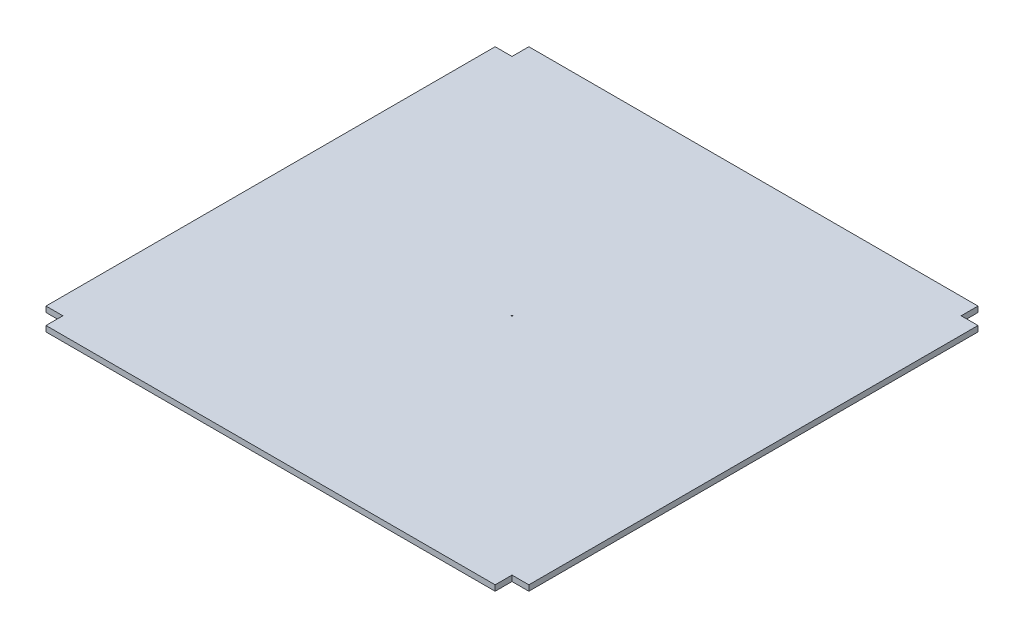
from build123d import *

# Parameters (mm, degrees)
BOSS_EXTRUDE1_DEPTH     = 10
SKETCH2_R               = 1
CUT_EXTRUDE1_DEPTH      = 1
CUT_EXTRUDE1_DEPTH_BACK = 11


with BuildPart() as part:
    # Sketch1 → Boss-Extrude1 (new body)
    with BuildSketch(Plane(origin=(0, 0, 0), x_dir=(1, 0, 0), z_dir=(0, 1, 0))):
        Polygon((-400, -430), (400, -430), (400, -400), (430, -400), (430, 400), (400, 400), (400, 430), (-400, 430), (-400, 400), (-430, 400), (-430, -400), (-400, -400), align=None)
    extrude(amount=BOSS_EXTRUDE1_DEPTH)

    # Sketch2 → Cut-Extrude1 (cut, two sides)
    with BuildSketch(Plane(origin=(0, 10, 0), x_dir=(1, 0, 0), z_dir=(0, 1, 0))) as cut_extrude1_sk:
        Circle(SKETCH2_R)
    extrude(amount=CUT_EXTRUDE1_DEPTH, mode=Mode.SUBTRACT)
    extrude(cut_extrude1_sk.sketch, amount=-CUT_EXTRUDE1_DEPTH_BACK, mode=Mode.SUBTRACT)


solid = part.part
